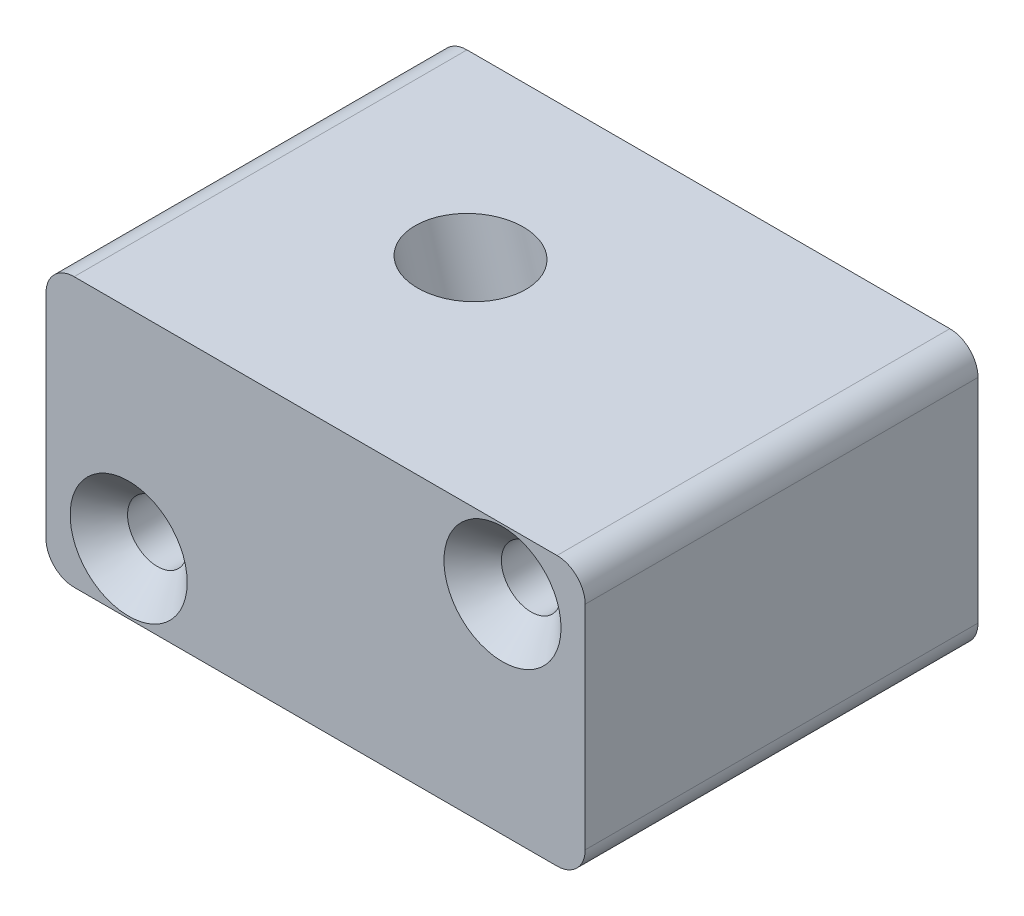
from build123d import *

# Parameters (mm, degrees)
BOSS_EXTRUDE1_DEPTH                             = 17.45
CSK_FOR_M5_FLAT_HEAD_MACHINE_SCREW1_D           = 5.3
CSK_FOR_M5_FLAT_HEAD_MACHINE_SCREW1_CSINK_D     = 10.4
CSK_FOR_M5_FLAT_HEAD_MACHINE_SCREW1_CSINK_ANGLE = 90
SKETCH24_W                                      = 4.699
SKETCH24_H                                      = 43.607186054


with BuildPart() as part:
    # Sketch1 → Boss-Extrude1 (new body, symmetric)
    with BuildSketch(Plane.XY):
        with BuildLine():
            Line((-21.45, -11.95), (21.45, -11.95))
            ThreePointArc((21.45, -11.95), (23.217766953, -11.217766953), (23.95, -9.45))
            Line((23.95, -9.45), (23.95, 9.45))
            ThreePointArc((23.95, 9.45), (23.217766953, 11.217766953), (21.45, 11.95))
            Line((21.45, 11.95), (-21.45, 11.95))
            ThreePointArc((-21.45, 11.95), (-23.217766953, 11.217766953), (-23.95, 9.45))
            Line((-23.95, 9.45), (-23.95, -9.45))
            ThreePointArc((-23.95, -9.45), (-23.217766953, -11.217766953), (-21.45, -11.95))
        make_face()
    extrude(amount=BOSS_EXTRUDE1_DEPTH, both=True)

    # CSK for M5 Flat Head Machine Screw1 (through all)
    with Locations(Plane.XY.offset(17.45)):
        with Locations((-16.605361405, -6.552011076), (16.605361405, 6.552011076)):
            CounterSinkHole(CSK_FOR_M5_FLAT_HEAD_MACHINE_SCREW1_D / 2, CSK_FOR_M5_FLAT_HEAD_MACHINE_SCREW1_CSINK_D / 2, counter_sink_angle=CSK_FOR_M5_FLAT_HEAD_MACHINE_SCREW1_CSINK_ANGLE)

    # Sketch24 → Cut-Revolve2 (revolve, cut)
    with BuildSketch(Plane(origin=(-1.518528381, -0.464260717, 0), x_dir=(0, 0, -1), z_dir=(0.956304756, 0.292371705, 0))):
        with Locations((3.9795, -0.045167625)):
            Rectangle(SKETCH24_W, SKETCH24_H)
    revolve(axis=Axis((-7.880076307, 20.343424977, -1.63), (0.292371705, -0.956304756, 0)), mode=Mode.SUBTRACT)


solid = part.part
